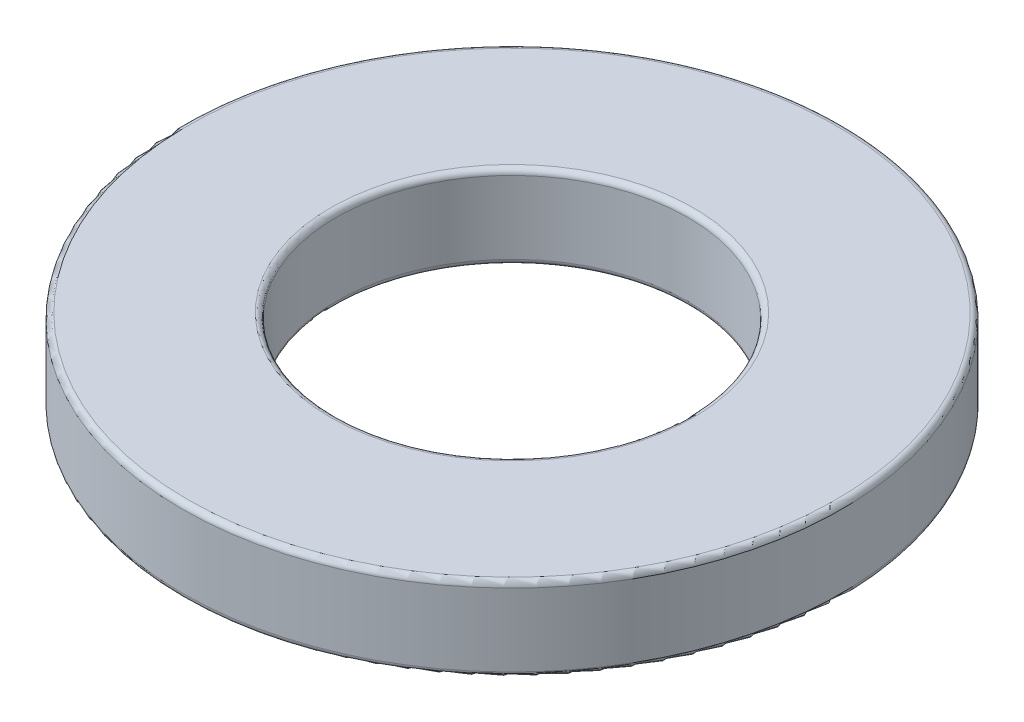
from build123d import *

# Parameters (mm, degrees)
SKETCH_1_R      = 5.9
SKETCH_1_R_2    = 3.15
EXTRUDE_1_DEPTH = 1.5
FILLET_1_R      = 0.1


with BuildPart() as part:
    # Эскиз1 → Бобышка-Вытянуть1 (new body)
    with BuildSketch(Plane(origin=(0, 0, 0), x_dir=(1, 0, 0), z_dir=(0, 1, 0))):
        Circle(SKETCH_1_R)
        Circle(SKETCH_1_R_2, mode=Mode.SUBTRACT)
    extrude(amount=EXTRUDE_1_DEPTH)

    # Скругление1
    fillet_1_edges = [part.edges().sort_by_distance(p)[0] for p in [
        (-5.9, 0, 0),
        (-5.9, 1.5, 0),
        (-3.15, 0, 0),
        (-3.15, 1.5, 0),
    ]]
    fillet(fillet_1_edges, radius=FILLET_1_R)


solid = part.part
